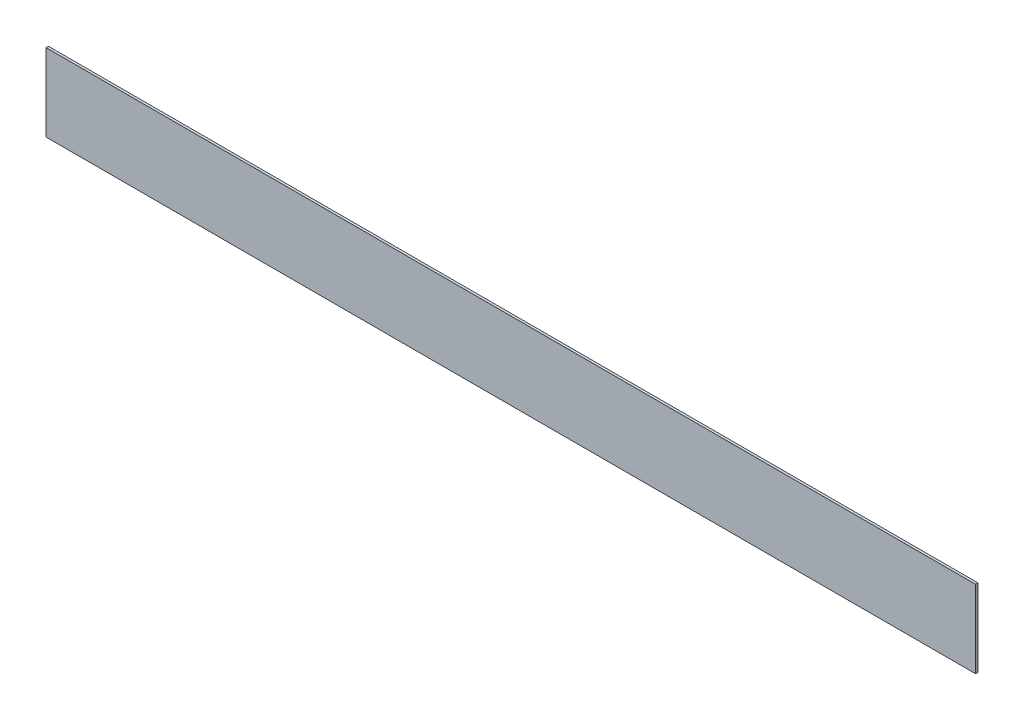
from build123d import *

# Parameters (mm, degrees)
SKETCH2_W           = 609.6
SKETCH2_H           = 50.8
BOSS_EXTRUDE1_DEPTH = 1.5875


with BuildPart() as part:
    # Sketch2 → Boss-Extrude1 (new body)
    with BuildSketch(Plane.XY):
        with Locations((304.8, 25.4)):
            Rectangle(SKETCH2_W, SKETCH2_H)
    extrude(amount=BOSS_EXTRUDE1_DEPTH)


solid = part.part
